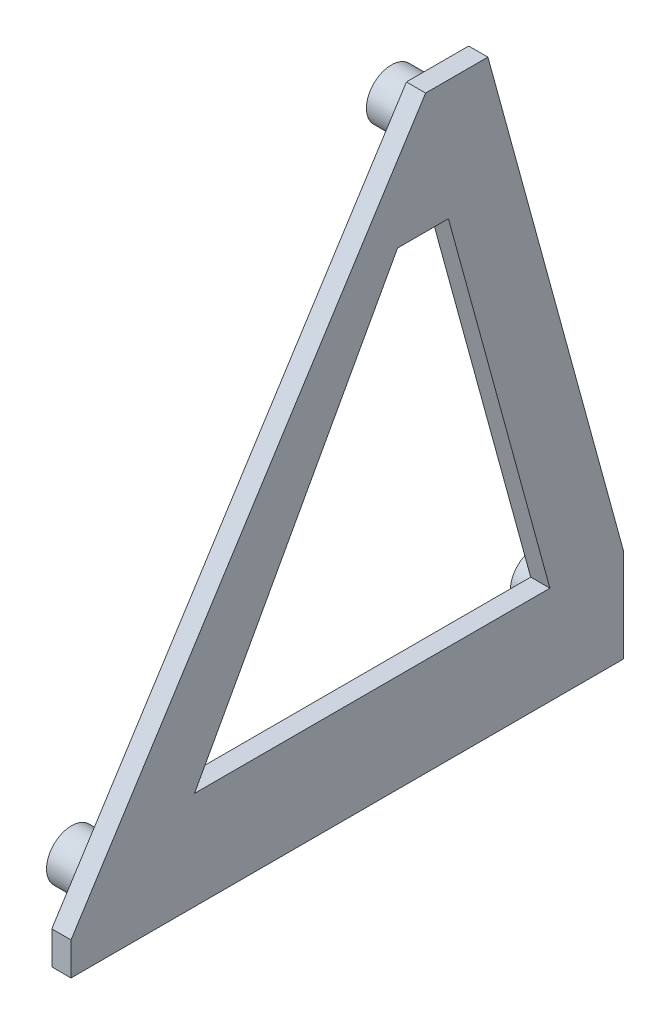
from build123d import *

# Parameters (mm, degrees)
SKETCH_1_W          = 63.552014958
SKETCH_1_H          = 75.18168128
EXTRUDE_1_DEPTH     = 2
CUT_EXTRUDE_3_DEPTH = 2
CUT_EXTRUDE_4_DEPTH = 2
SKETCH_2_R          = 2.6
SKETCH_2_R_2        = 1.5
EXTRUDE_2_DEPTH     = 6


with BuildPart() as part:
    # 草图1 → 凸台-拉伸1 (new body)
    with BuildSketch(Plane(origin=(0, 0, 0), x_dir=(0, 0, -1), z_dir=(1, 0, 0))):
        with Locations((-6.130256719, 2.766182452)):
            Rectangle(SKETCH_1_W, SKETCH_1_H)
    extrude(amount=EXTRUDE_1_DEPTH)

    # 草图3 → 切除-拉伸3 (cut)
    with BuildSketch(Plane(origin=(2, 0, 0), x_dir=(0, 0, -1), z_dir=(1, 0, 0))):
        Polygon((-37.906264198, -19.734560887), (-37.906264198, 40.357023092), (25.64575076, 40.357023092), (25.64575076, -13.40384327), (25.64575076, -23.166877668), (25.64575076, -34.824658188), (-37.906264198, -34.824658188), (-37.906264198, -23.166877668), align=None)
        Polygon((3.861598797, 38.157182144), (-33.05487502, -19.734560887), (-33.05487502, -23.166877668), (24.455499481, -23.166877668), (24.455499481, -13.40384327), (10.344863827, 38.157182144), align=None, mode=Mode.SUBTRACT)
    extrude(amount=-CUT_EXTRUDE_3_DEPTH, mode=Mode.SUBTRACT)

    # 草图4 → 切除-拉伸4 (cut)
    with BuildSketch(Plane(origin=(2, 0, 0), x_dir=(0, 0, -1), z_dir=(1, 0, 0))):
        Polygon((0.937037541, 25.644128731), (-20.204452885, -12.953479978), (16.800310672, -12.953479978), (6.235289924, 25.644128731), align=None)
    extrude(amount=-CUT_EXTRUDE_4_DEPTH, mode=Mode.SUBTRACT)

    # 草图2 → 凸台-拉伸2 (add)
    with BuildSketch(Plane(origin=(2, 0, 0), x_dir=(0, 0, -1), z_dir=(1, 0, 0))):
        with Locations((6.295781653, 33.876700988)):
            Circle(SKETCH_2_R)
        with Locations((6.295781653, 33.876700988)):
            Circle(SKETCH_2_R_2, mode=Mode.SUBTRACT)
        with Locations((-27.006264198, -18.064263021)):
            Circle(SKETCH_2_R)
        with Locations((-27.006264198, -18.064263021)):
            Circle(SKETCH_2_R_2, mode=Mode.SUBTRACT)
        with Locations((21.283382726, -17.064263021)):
            Circle(SKETCH_2_R)
        with Locations((21.283382726, -17.064263021)):
            Circle(SKETCH_2_R_2, mode=Mode.SUBTRACT)
    extrude(amount=-EXTRUDE_2_DEPTH)


solid = part.part
